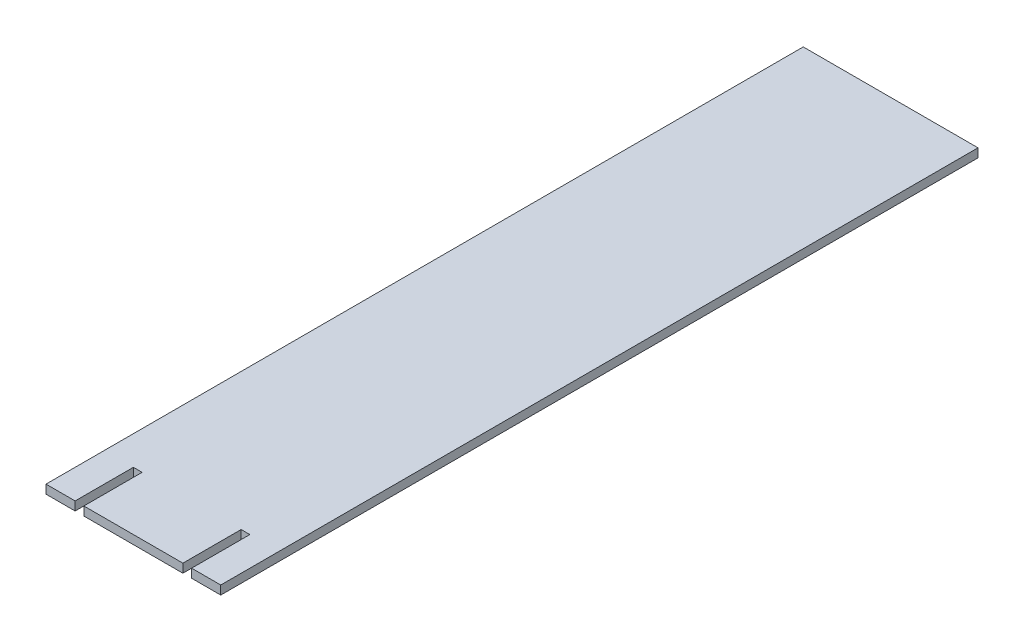
from build123d import *

# Parameters (mm, degrees)
BOSS_EXTRUDE1_DEPTH = 3


with BuildPart() as part:
    # Sketch1 → Boss-Extrude1 (new body)
    with BuildSketch(Plane(origin=(0, 0, 0), x_dir=(1, 0, 0), z_dir=(0, 1, 0))):
        Polygon((0, 0), (10, 0), (10, 20), (13, 20), (13, 0), (47, 0), (47, 20), (50, 20), (50, 0), (60, 0), (60, 260), (0, 260), align=None)
    extrude(amount=BOSS_EXTRUDE1_DEPTH)


solid = part.part
